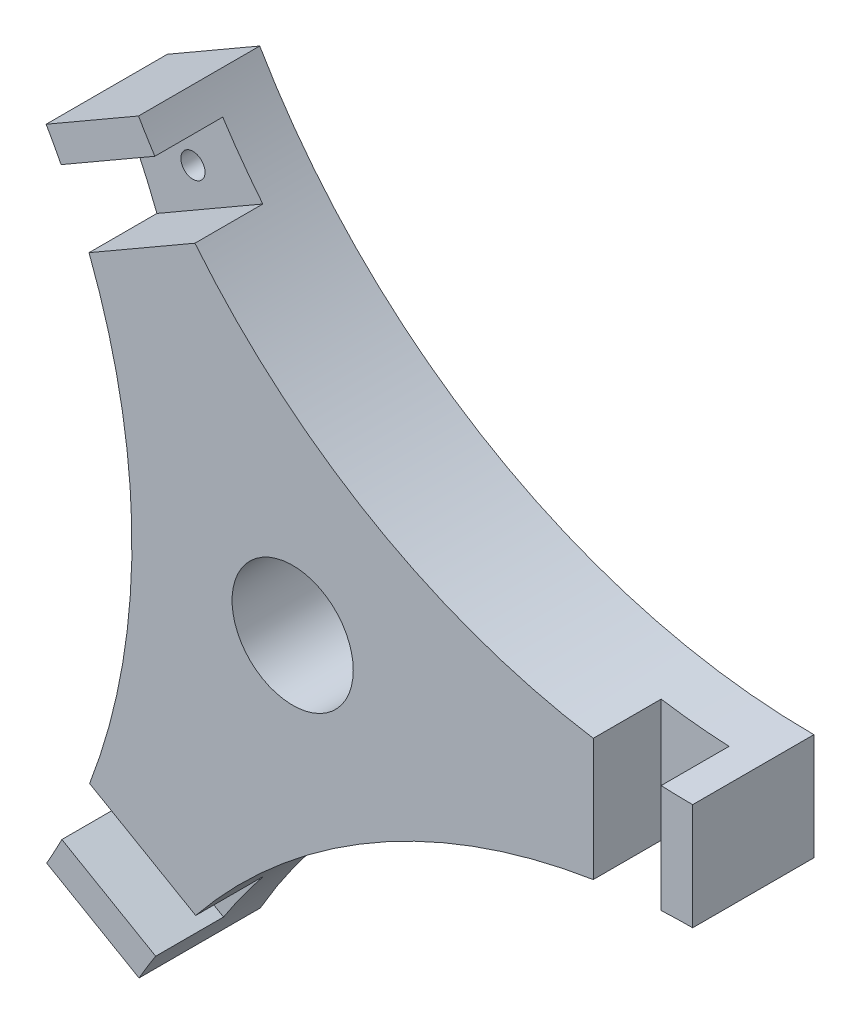
from build123d import *

# Parameters (mm, degrees)
CROQUIS1_R              = 6.25
CROQUIS1_R_2            = 1.25
SALIENTE_EXTRUIR1_DEPTH = 12.5
CROQUIS2_W              = 7
CROQUIS2_H              = 18.683696708
CORTAR_EXTRUIR1_DEPTH   = 7


with BuildPart() as part:
    # Croquis1 → Saliente-Extruir1 (new body)
    with BuildSketch(Plane.XY):
        with BuildLine():
            Line((41.25, -5.5), (41.25, 5.5))
            ThreePointArc((41.25, 5.5), (8.272659528, 14.321014207), (-15.896844885, 38.428074017))
            Line((-15.896844885, 38.428074017), (-25.423124326, 32.928074017))
            ThreePointArc((-25.423124326, 32.928074017), (-16.573676481, -0.041647684), (-25.36625048, -33.026582408))
            Line((-25.36625048, -33.026582408), (-15.839971039, -38.526582408))
            ThreePointArc((-15.839971039, -38.526582408), (8.287921588, -14.377874913), (41.25, -5.5))
        make_face()
        Circle(CROQUIS1_R, mode=Mode.SUBTRACT)
        with Locations((34.5, 0)):
            Circle(CROQUIS1_R_2, mode=Mode.SUBTRACT)
        with Locations((-17.22811076, -29.930910932)):
            Circle(CROQUIS1_R_2, mode=Mode.SUBTRACT)
        with Locations((-17.284984605, 29.832402542)):
            Circle(CROQUIS1_R_2, mode=Mode.SUBTRACT)
    extrude(amount=SALIENTE_EXTRUIR1_DEPTH)

    # Croquis2 → Cortar-Extruir1 (cut)
    with BuildSketch(Plane.XY.offset(12.5)):
        with Locations((34.5, -0.520271759)):
            Rectangle(CROQUIS2_W, CROQUIS2_H)
        Polygon((-11.360290568, -37.319753641), (-7.860290568, -31.257575815), (-24.040846553, -21.915727461), (-27.540846553, -27.977905287), align=None)
        Polygon((-26.639709432, 28.498177047), (-23.139709432, 22.43599922), (-6.959153447, 31.777847574), (-10.459153447, 37.8400254), align=None)
    extrude(amount=-CORTAR_EXTRUIR1_DEPTH, mode=Mode.SUBTRACT)


solid = part.part
